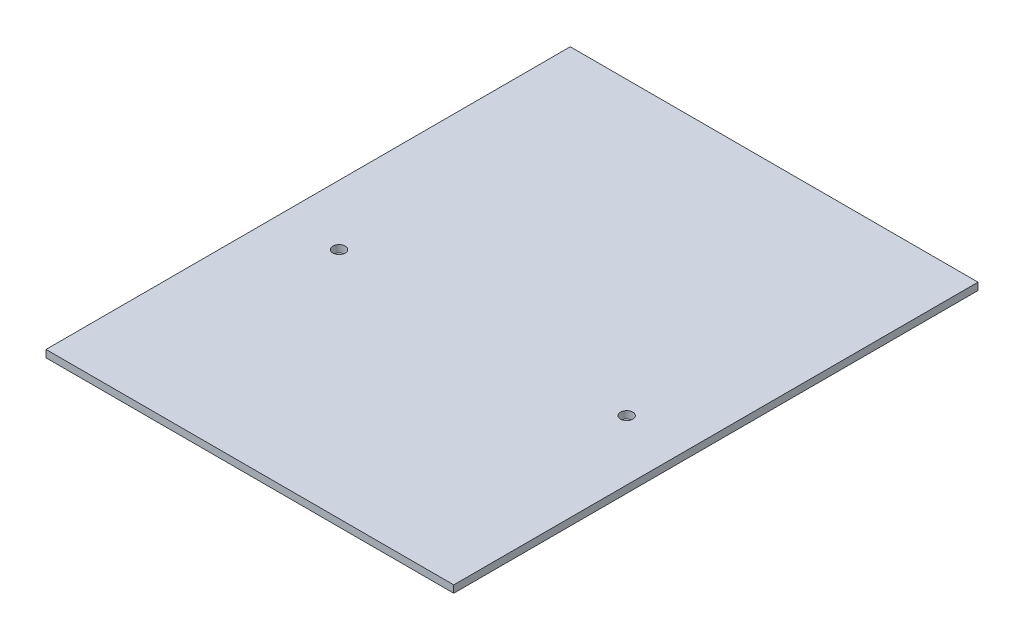
from build123d import *

# Parameters (mm, degrees)
SKETCH1_W                        = 355.6
SKETCH1_H                        = 457.2
BOSS_EXTRUDE1_DEPTH              = 6.35
F_27_64_0_42188_DIAMETER_HOLE1_D = 10.715752


with BuildPart() as part:
    # Sketch1 → Boss-Extrude1 (new body)
    with BuildSketch(Plane(origin=(0, 0, 0), x_dir=(1, 0, 0), z_dir=(0, 1, 0))):
        with Locations((177.8, 228.6)):
            Rectangle(SKETCH1_W, SKETCH1_H)
    extrude(amount=BOSS_EXTRUDE1_DEPTH)

    # 27/64 (0.42188) Diameter Hole1 (through all)
    with Locations(Plane(origin=(0, 6.35, 0), x_dir=(1, 0, 0), z_dir=(0, 1, 0))):
        with Locations((303.2125, 203.2), (52.3875, 203.2)):
            Hole(F_27_64_0_42188_DIAMETER_HOLE1_D / 2)


solid = part.part
